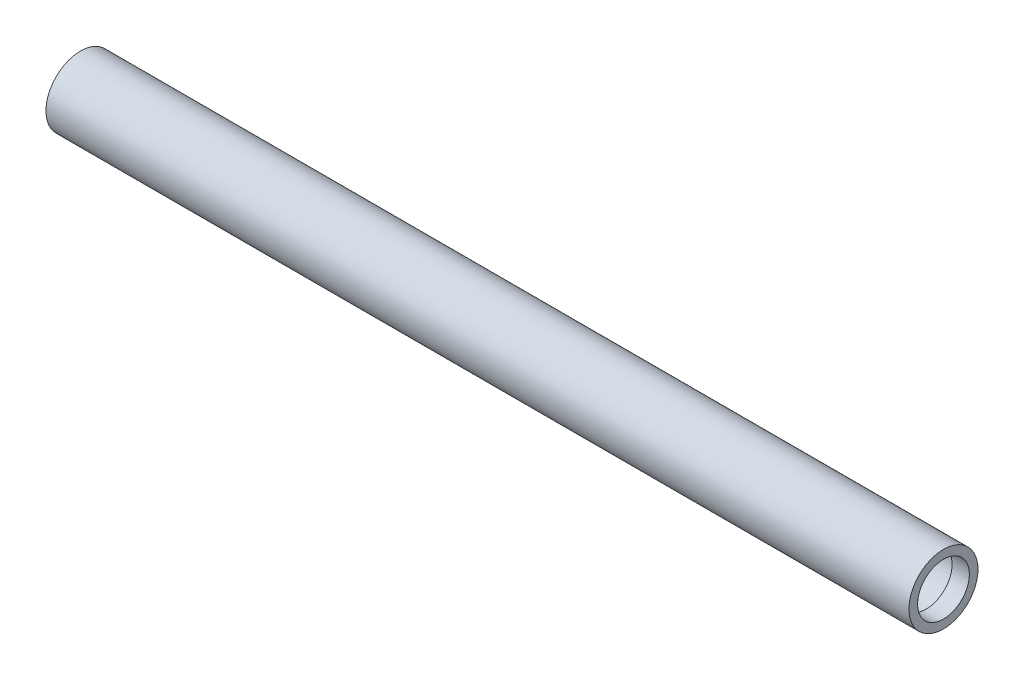
from build123d import *

# Parameters (mm, degrees)
SKETCH1_R           = 20
SKETCH1_R_2         = 18
BOSS_EXTRUDE1_DEPTH = 500
SKETCH2_R           = 18
SKETCH2_R_2         = 10
BOSS_EXTRUDE2_DEPTH = 10
SKETCH5_R           = 18
SKETCH5_R_2         = 15
BOSS_EXTRUDE3_DEPTH = 10


with BuildPart() as part:
    # Sketch1 → Boss-Extrude1 (new body)
    with BuildSketch(Plane(origin=(0, 0, 0), x_dir=(0, 0, -1), z_dir=(1, 0, 0))):
        Circle(SKETCH1_R)
        Circle(SKETCH1_R_2, mode=Mode.SUBTRACT)
    extrude(amount=BOSS_EXTRUDE1_DEPTH)

    # Sketch2 → Boss-Extrude2 (add)
    with BuildSketch(Plane.ZY):
        Circle(SKETCH2_R)
        Circle(SKETCH2_R_2, mode=Mode.SUBTRACT)
    extrude(amount=-BOSS_EXTRUDE2_DEPTH)

    # Sketch5 → Boss-Extrude3 (add)
    with BuildSketch(Plane(origin=(500, 0, 0), x_dir=(0, 0, -1), z_dir=(1, 0, 0))):
        Circle(SKETCH5_R)
        Circle(SKETCH5_R_2, mode=Mode.SUBTRACT)
    extrude(amount=-BOSS_EXTRUDE3_DEPTH)


solid = part.part
